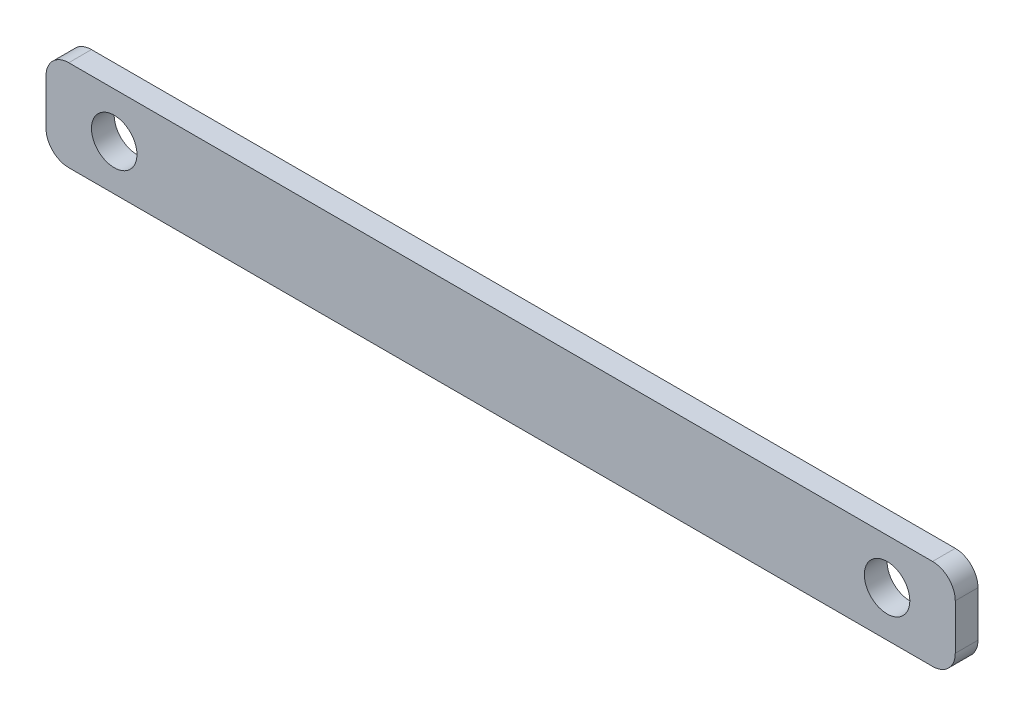
from build123d import *

# Parameters (mm, degrees)
SKETCH1_R           = 10
BOSS_EXTRUDE1_DEPTH = 5


with BuildPart() as part:
    # Sketch1 → Boss-Extrude1 (new body, symmetric)
    with BuildSketch(Plane.XY):
        with BuildLine():
            Line((-190, 151.018152993), (190, 151.018152993))
            ThreePointArc((190, 151.018152993), (197.071067812, 148.089220805), (200, 141.018152993))
            Line((200, 141.018152993), (200, 121.018152993))
            ThreePointArc((200, 121.018152993), (197.071067812, 113.947085181), (190, 111.018152993))
            Line((190, 111.018152993), (-190, 111.018152993))
            ThreePointArc((-190, 111.018152993), (-197.071067812, 113.947085181), (-200, 121.018152993))
            Line((-200, 121.018152993), (-200, 141.018152993))
            ThreePointArc((-200, 141.018152993), (-197.071067812, 148.089220805), (-190, 151.018152993))
        make_face()
        with Locations((-170, 131.018152993)):
            Circle(SKETCH1_R, mode=Mode.SUBTRACT)
        with Locations((170, 131.018152993)):
            Circle(SKETCH1_R, mode=Mode.SUBTRACT)
    extrude(amount=BOSS_EXTRUDE1_DEPTH, both=True)


solid = part.part
